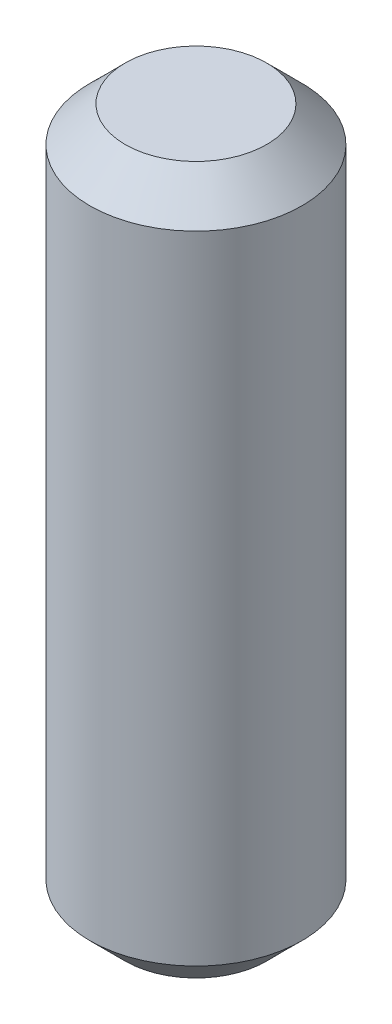
from build123d import *

# Parameters (mm, degrees)
SKETCH1_R           = 1.5
BOSS_EXTRUDE1_DEPTH = 10
CHAMFER1_SIZE       = 0.5


with BuildPart() as part:
    # Sketch1 → Boss-Extrude1 (new body)
    with BuildSketch(Plane(origin=(0, 0, 0), x_dir=(1, 0, 0), z_dir=(0, 1, 0))):
        Circle(SKETCH1_R)
    extrude(amount=BOSS_EXTRUDE1_DEPTH)

    # Chamfer1
    chamfer1_edges = [part.edges().sort_by_distance(p)[0] for p in [
        (-1.5, 0, 0),
        (-1.5, 10, 0),
    ]]
    chamfer(chamfer1_edges, length=CHAMFER1_SIZE)


solid = part.part
